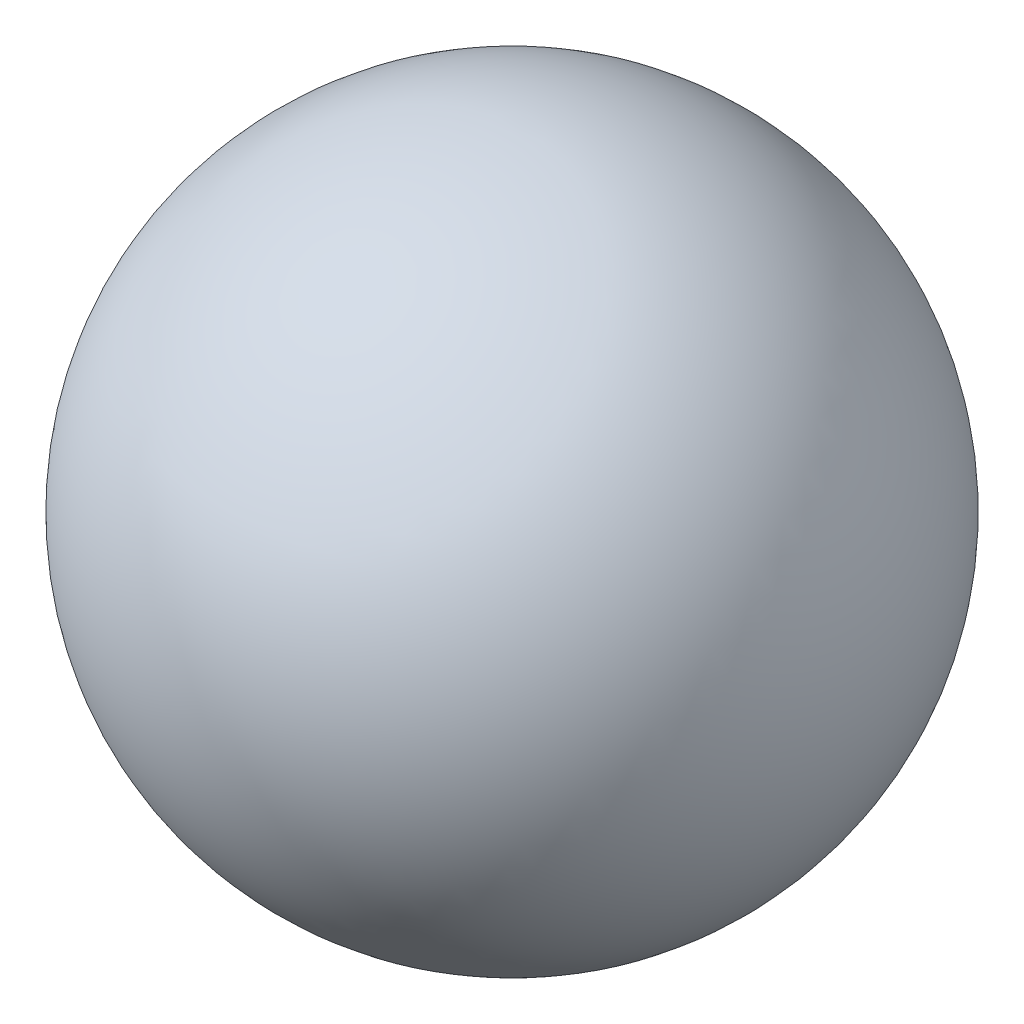
from build123d import *


with BuildPart() as part:
    # 草图1 → 旋转2 (revolve)
    with BuildSketch(Plane.XY):
        with BuildLine():
            Line((0, 21.25), (0, -21.25))
            ThreePointArc((0, -21.25), (21.25, 0), (0, 21.25))
        make_face()
    revolve(axis=Axis((0, 21.25, 0), (0, -1, 0)))


solid = part.part
